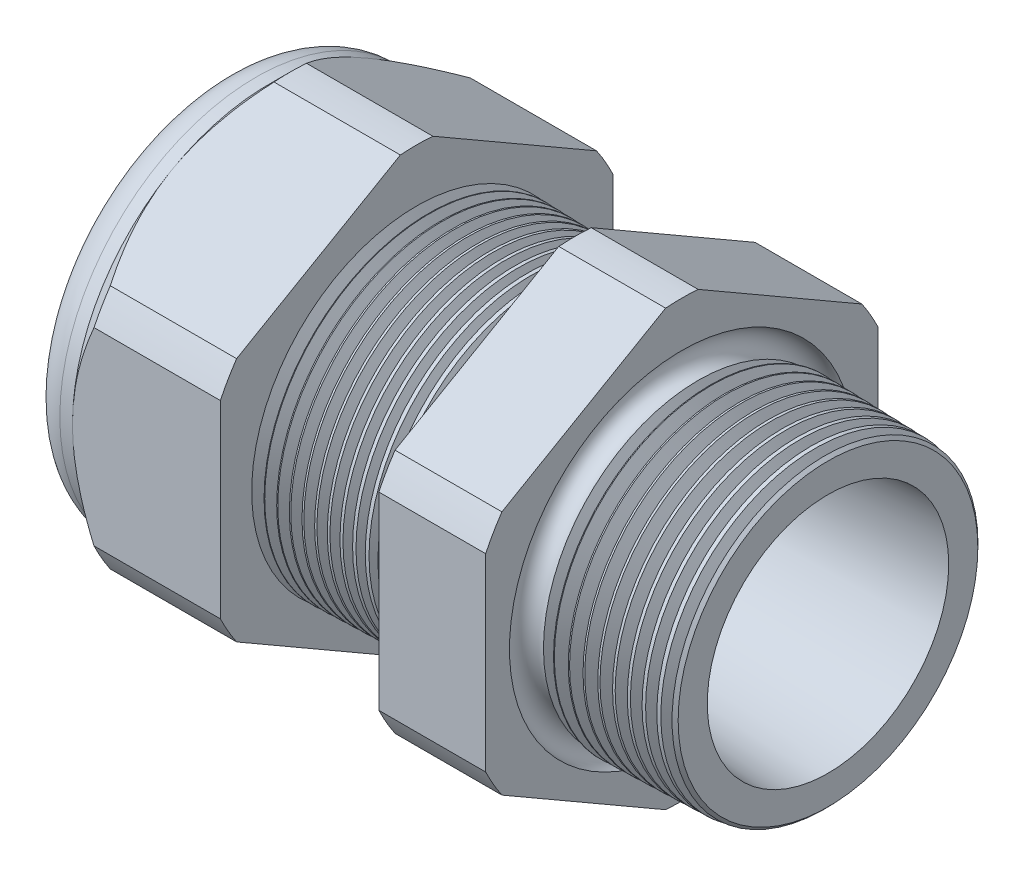
from build123d import *

# Parameters (mm, degrees)
SKETCH12_OUTSIDE_W = 65.136
SKETCH12_OUTSIDE_H = 65.136
CUT_EXTRUDE2_DEPTH = 35.03
FILLET4_R          = 2.032
SKETCH19_OUTSIDE_W = 40.13
SKETCH19_OUTSIDE_H = 42.756
SKETCH19_OUTSIDE_R = 11.938
CUT_EXTRUDE3_DEPTH = 1.999996
CUT_EXTRUDE3_DRAFT = -45
CHAMFER1_SIZE      = 0.260919487
CHAMFER1_SIZE2     = 0.254
SKETCH21_R         = 5.969
PLUG_DEPTH         = 6.35
SKETCH22_R         = 5.715
CUT_EXTRUDE4_DEPTH = 0.508
LPATTERN1_COUNT    = 13
LPATTERN1_PITCH    = 0.762
LPATTERN2_COUNT    = 10
LPATTERN2_PITCH    = 0.889
SKETCH32_R         = 0.889


with BuildPart() as part:
    # Sketch10 → Revolve2 (revolve)
    with BuildSketch(Plane.XY, mode=Mode.PRIVATE) as revolve2_sk:
        Polygon((-35.814, 5.969), (-24.014, 5.969), (1.016, 7.345566383), (1.016, 9.377566383), (-7.874, 9.610359226), (-7.874, 23.876), (-14.374, 23.876), (-14.374, 9.780567716), (-24.014, 10.033), (-24.014, 23.876), (-33.014, 23.876), (-33.014, 11.938), (-35.814, 11.938), align=None)
    revolve(revolve2_sk.sketch.rotate(Axis((0, 0, 0), (-1, 0, 0)), 90), axis=Axis((0, 0, 0), (-1, 0, 0)))  # turned: the seam where the file's is

    # Sketch12 outside → Cut-Extrude2 (cut, through all)
    with BuildSketch(Plane.ZY.offset(33.014)):
        Rectangle(SKETCH12_OUTSIDE_W, SKETCH12_OUTSIDE_H)
        with BuildLine():
            Line((-0.98819228, 13.214281948), (-10.94980772, 7.462940592))
            ThreePointArc((-10.94980772, 7.462940592), (-11.47585851, 6.62559), (-11.938, 5.751341356))
            Line((-11.938, 5.751341356), (-11.938, -5.751341356))
            ThreePointArc((-11.938, -5.751341356), (-11.47585851, -6.62559), (-10.94980772, -7.462940592))
            Line((-10.94980772, -7.462940592), (-0.98819228, -13.214281948))
            ThreePointArc((-0.98819228, -13.214281948), (0, -13.25118), (0.98819228, -13.214281948))
            Line((0.98819228, -13.214281948), (10.94980772, -7.462940592))
            ThreePointArc((10.94980772, -7.462940592), (11.47585851, -6.62559), (11.938, -5.751341356))
            Line((11.938, -5.751341356), (11.938, 5.751341356))
            ThreePointArc((11.938, 5.751341356), (11.47585851, 6.62559), (10.94980772, 7.462940592))
            Line((10.94980772, 7.462940592), (0.98819228, 13.214281948))
            ThreePointArc((0.98819228, 13.214281948), (0, 13.25118), (-0.98819228, 13.214281948))
        make_face(mode=Mode.SUBTRACT)
    extrude(amount=-CUT_EXTRUDE2_DEPTH, mode=Mode.SUBTRACT)

    # Fillet4
    fillet4_edges = [part.edges().sort_by_distance(p)[0] for p in [
        (-35.814, 0, 11.938),
    ]]
    fillet(fillet4_edges, radius=FILLET4_R)


with BuildPart() as cut_extrude3_tool:
    # Sketch19 outside → Cut-Extrude3 (with draft: the straight prism first)
    with BuildSketch(Plane.ZY.offset(33.014)):
        Rectangle(SKETCH19_OUTSIDE_W, SKETCH19_OUTSIDE_H)
        Circle(SKETCH19_OUTSIDE_R, mode=Mode.SUBTRACT)
    extrude(amount=-CUT_EXTRUDE3_DEPTH)
    # Cut-Extrude3: the draft: its side faces are tilted about the plane it starts from
    cut_extrude3_sides = [cut_extrude3_tool.faces().sort_by_distance(p)[0] for p in [
        (-32.014002, -21.378, 0),
        (-32.014002, 0, 20.065),
        (-32.014002, 21.378, 0),
        (-32.014002, 0, -20.065),
        (-32.014002, 0, -11.938),
    ]]
    draft(cut_extrude3_sides, Plane.ZY.offset(33.014), CUT_EXTRUDE3_DRAFT)


with BuildPart() as part_1:
    add(part.part)

    # Cut-Extrude3: cut by cut_extrude3_tool
    add(cut_extrude3_tool.part, mode=Mode.SUBTRACT)

    # Chamfer1
    chamfer1_edges = [part_1.edges().sort_by_distance(p)[0] for p in [
        (1.016, 0, 9.377566383),
    ]]
    chamfer1_side = [part_1.faces().sort_by_distance(p)[0] for p in [
        (1.016, 0, 7.610804014),
    ]]
    chamfer(chamfer1_edges, length=CHAMFER1_SIZE, length2=CHAMFER1_SIZE2, reference=chamfer1_side[0])

    # Sketch29 → Cut-Revolve1 (revolve, cut)
    with BuildSketch(Plane.XY, mode=Mode.PRIVATE) as cut_revolve1_sk:
        Polygon((-24.014, 10.033), (-23.281016419, 10.013806149), (-23.664130572, 9.388620673), align=None)
    cut_revolve1 = revolve(cut_revolve1_sk.sketch.rotate(Axis((0, 0, 0), (-1, 0, 0)), 90), axis=Axis((0, 0, 0), (-1, 0, 0)), mode=Mode.SUBTRACT)  # turned: the seam where the file's is

    # LPattern1: Cut-Revolve1 ×13
    with Locations(*[(i * LPATTERN1_PITCH, 0, 0) for i in range(1, LPATTERN1_COUNT)]):
        add(cut_revolve1, mode=Mode.SUBTRACT)

    # Sketch30 → Cut-Revolve2 (revolve, cut)
    with BuildSketch(Plane.XY, mode=Mode.PRIVATE) as cut_revolve2_sk:
        Polygon((-7.874, 9.610359226), (-6.994419703, 9.587326605), (-7.454156686, 8.837104034), align=None)
    cut_revolve2 = revolve(cut_revolve2_sk.sketch.rotate(Axis((0, 0, 0), (-1, 0, 0)), 270), axis=Axis((0, 0, 0), (-1, 0, 0)), mode=Mode.SUBTRACT)  # turned: the seam where the file's is

    # LPattern2: Cut-Revolve2 ×10
    with Locations(*[(i * LPATTERN2_PITCH, 0, 0) for i in range(1, LPATTERN2_COUNT)]):
        add(cut_revolve2, mode=Mode.SUBTRACT)

    # Sketch32 → Cut-Revolve3 (revolve, cut)
    with BuildSketch(Plane.XY, mode=Mode.PRIVATE) as cut_revolve3_sk:
        with Locations((-7.747, 9.610359226)):
            Circle(SKETCH32_R)
    revolve(cut_revolve3_sk.sketch.rotate(Axis((0, 0, 0), (-1, 0, 0)), 270), axis=Axis((0, 0, 0), (-1, 0, 0)), mode=Mode.SUBTRACT)  # turned: the seam where the file's is


with BuildPart() as body_2:
    # Sketch21 → plug (new body)
    with BuildSketch(Plane.ZY.offset(35.814)):
        Circle(SKETCH21_R)
    extrude(amount=-PLUG_DEPTH)

    # Sketch22 → Cut-Extrude4 (cut)
    with BuildSketch(Plane.ZY.offset(35.814)):
        Circle(SKETCH22_R)
    extrude(amount=-CUT_EXTRUDE4_DEPTH, mode=Mode.SUBTRACT)


solid = Compound([part_1.part, body_2.part])
